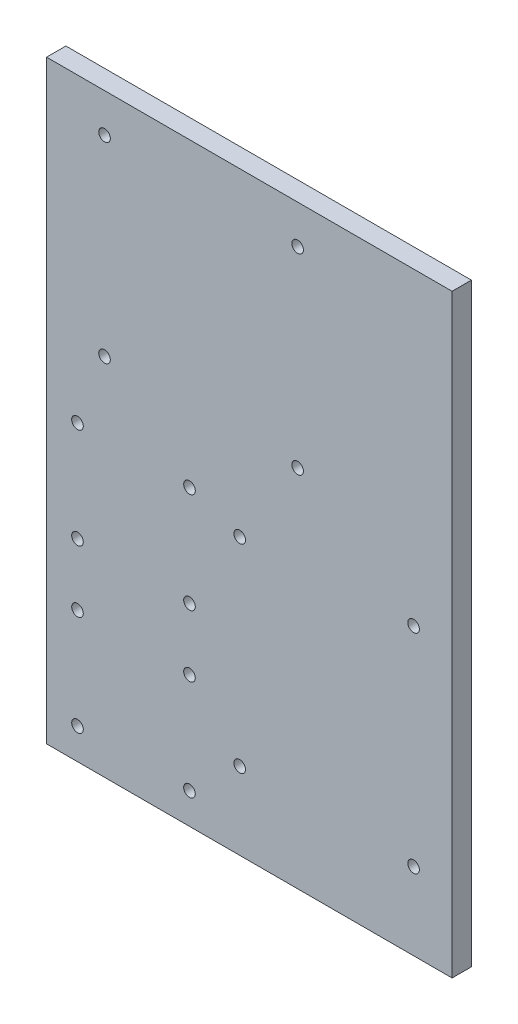
from build123d import *

# Parameters (mm, degrees)
SKETCH1_W           = 105
SKETCH1_H           = 154
BOSS_EXTRUDE1_DEPTH = 5
SKETCH3_R           = 1.5
CUT_EXTRUDE1_DEPTH  = 10
SKETCH4_R           = 1.5
CUT_EXTRUDE2_DEPTH  = 136.687140142
SKETCH6_R           = 1.5
CUT_EXTRUDE4_DEPTH  = 136.687140142


with BuildPart() as part:
    # Sketch1 → Boss-Extrude1 (new body)
    with BuildSketch(Plane.XY):
        with Locations((12.5, -42)):
            Rectangle(SKETCH1_W, SKETCH1_H)
    extrude(amount=BOSS_EXTRUDE1_DEPTH)

    # Sketch3 → Cut-Extrude1 (cut)
    with BuildSketch(Plane(origin=(0, 0, 0), x_dir=(-1, 0, 0), z_dir=(0, 0, -1))):
        with Locations((32, -43)):
            Circle(SKETCH3_R)
        with Locations((32, -85)):
            Circle(SKETCH3_R)
        with Locations((3, -111)):
            Circle(SKETCH3_R)
        with Locations((3, -43)):
            Circle(SKETCH3_R)
        with Locations((32, -111)):
            Circle(SKETCH3_R)
        with Locations((3, -85)):
            Circle(SKETCH3_R)
        with Locations((3, -69)):
            Circle(SKETCH3_R)
        with Locations((32, -69)):
            Circle(SKETCH3_R)
    extrude(amount=-CUT_EXTRUDE1_DEPTH, mode=Mode.SUBTRACT)

    # Sketch4 → Cut-Extrude2 (cut, through all)
    with BuildSketch(Plane(origin=(0, 0, 0), x_dir=(-1, 0, 0), z_dir=(0, 0, -1))):
        with Locations((-25, 25)):
            Circle(SKETCH4_R)
        with Locations((25, 25)):
            Circle(SKETCH4_R)
        with Locations((25, -24.60667729)):
            Circle(SKETCH4_R)
        with Locations((-25, -24.60667729)):
            Circle(SKETCH4_R)
    extrude(amount=-CUT_EXTRUDE2_DEPTH, mode=Mode.SUBTRACT)

    # Sketch6 → Cut-Extrude4 (cut, through all)
    with BuildSketch(Plane(origin=(0, 0, 0), x_dir=(-1, 0, 0), z_dir=(0, 0, -1))):
        with Locations((-10, -47.56)):
            Circle(SKETCH6_R)
        with Locations((-55.018401793, -45.02)):
            Circle(SKETCH6_R)
        with Locations((-55.018401793, -99)):
            Circle(SKETCH6_R)
        with Locations((-10, -99)):
            Circle(SKETCH6_R)
    extrude(amount=-CUT_EXTRUDE4_DEPTH, mode=Mode.SUBTRACT)


solid = part.part
